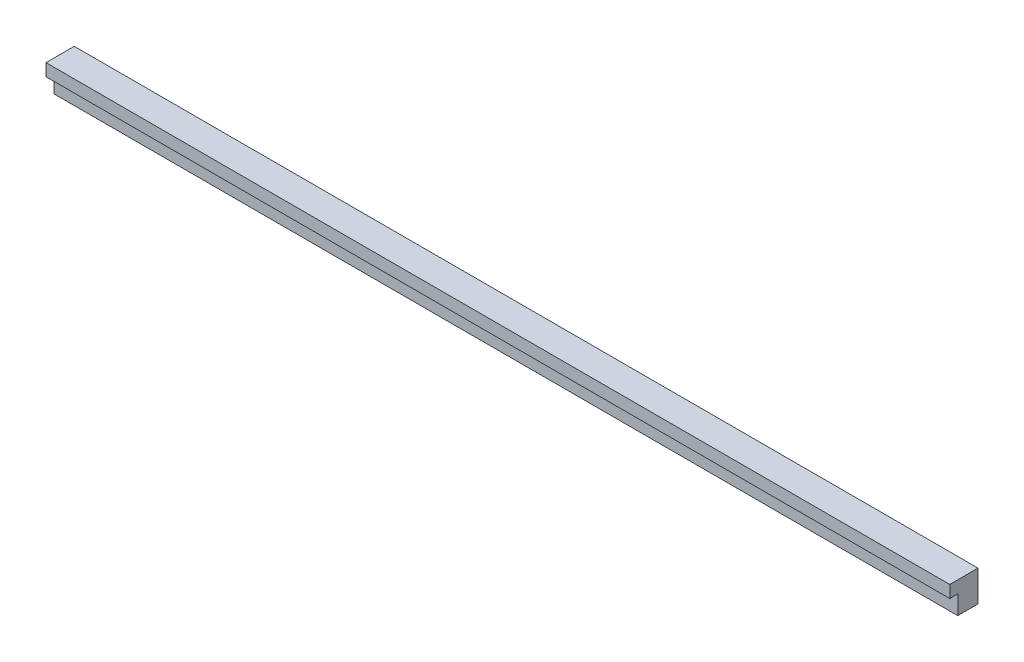
from build123d import *

# Parameters (mm, degrees)
ESQUISSE1_W        = 960
ESQUISSE1_H        = 33
BOSS_EXTRU_1_DEPTH = 21.5
ESQUISSE2_W        = 960
ESQUISSE2_H        = 13
BOSS_EXTRU_2_DEPTH = 8.5


with BuildPart() as part:
    # Esquisse1 → Boss.-Extru.1 (new body)
    with BuildSketch(Plane.XY):
        with Locations((161, 178.5)):
            Rectangle(ESQUISSE1_W, ESQUISSE1_H)
    extrude(amount=BOSS_EXTRU_1_DEPTH)

    # Esquisse2 → Boss.-Extru.2 (add)
    with BuildSketch(Plane.XY.offset(21.5)):
        with Locations((161, 188.5)):
            Rectangle(ESQUISSE2_W, ESQUISSE2_H)
    extrude(amount=BOSS_EXTRU_2_DEPTH)


solid = part.part
